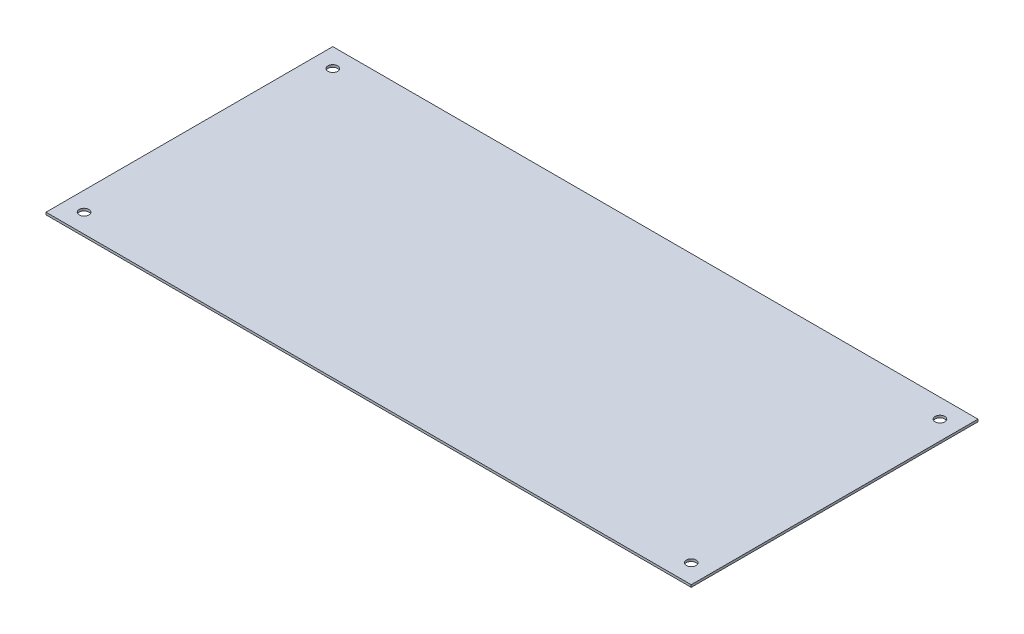
from build123d import *

# Parameters (mm, degrees)
SKETCH2_W           = 441
SKETCH2_H           = 196
BOSS_EXTRUDE1_DEPTH = 1.6
SKETCH5_R           = 3.3
CUT_EXTRUDE1_DEPTH  = 1.6


with BuildPart() as part:
    # Sketch2 → Boss-Extrude1 (new body)
    with BuildSketch(Plane(origin=(0, 0, 0), x_dir=(1, 0, 0), z_dir=(0, 1, 0))):
        with Locations((-2.5, -2)):
            Rectangle(SKETCH2_W, SKETCH2_H)
    extrude(amount=BOSS_EXTRUDE1_DEPTH)

    # Sketch5 → Cut-Extrude1 (cut)
    with BuildSketch(Plane(origin=(0, 1.6, 0), x_dir=(1, 0, 0), z_dir=(0, 1, 0))):
        with Locations((-210, 83)):
            Circle(SKETCH5_R)
        with Locations((205, 83)):
            Circle(SKETCH5_R)
        with Locations((205, -87)):
            Circle(SKETCH5_R)
        with Locations((-210, -87)):
            Circle(SKETCH5_R)
    extrude(amount=-CUT_EXTRUDE1_DEPTH, mode=Mode.SUBTRACT)


solid = part.part
